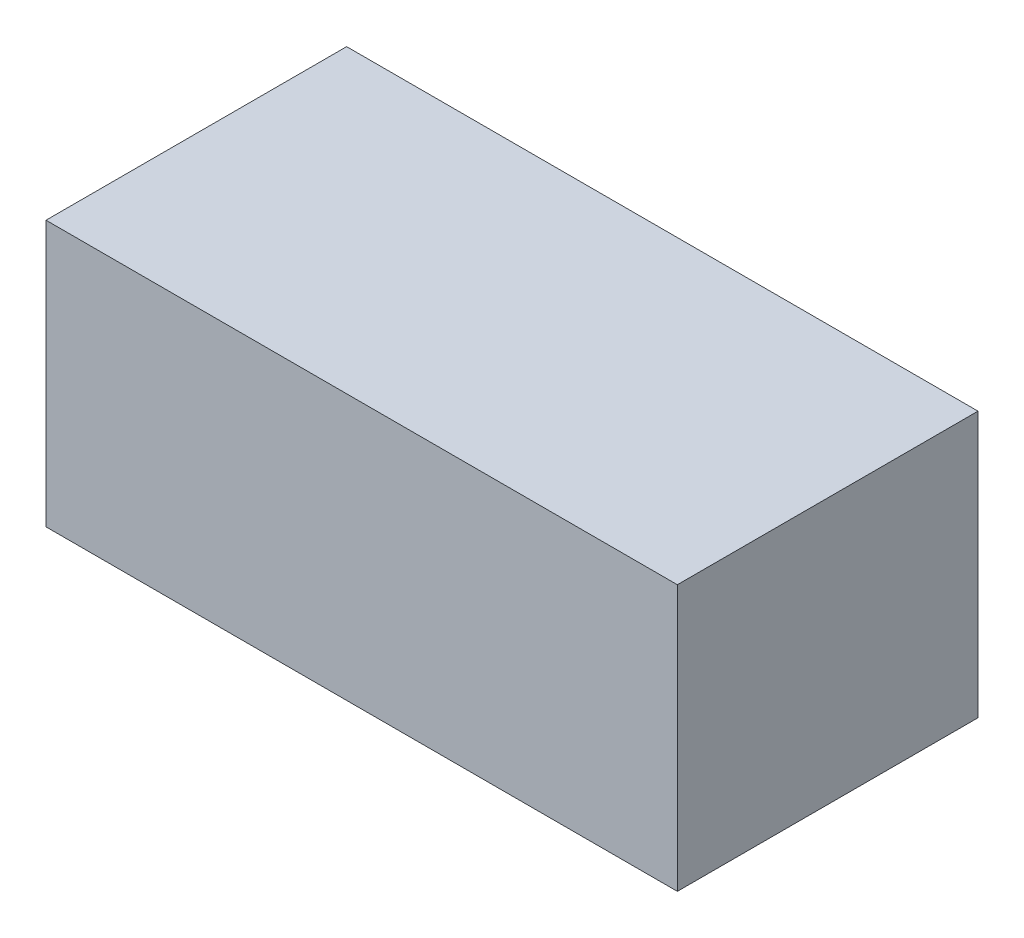
from build123d import *

# Parameters (mm, degrees)
SKETCH1_W           = 63
SKETCH1_H           = 30
BOSS_EXTRUDE1_DEPTH = 26.5


with BuildPart() as part:
    # Sketch1 → Boss-Extrude1 (new body)
    with BuildSketch(Plane(origin=(0, 0, 0), x_dir=(1, 0, 0), z_dir=(0, 1, 0))):
        Rectangle(SKETCH1_W, SKETCH1_H)
    extrude(amount=BOSS_EXTRUDE1_DEPTH)


solid = part.part
